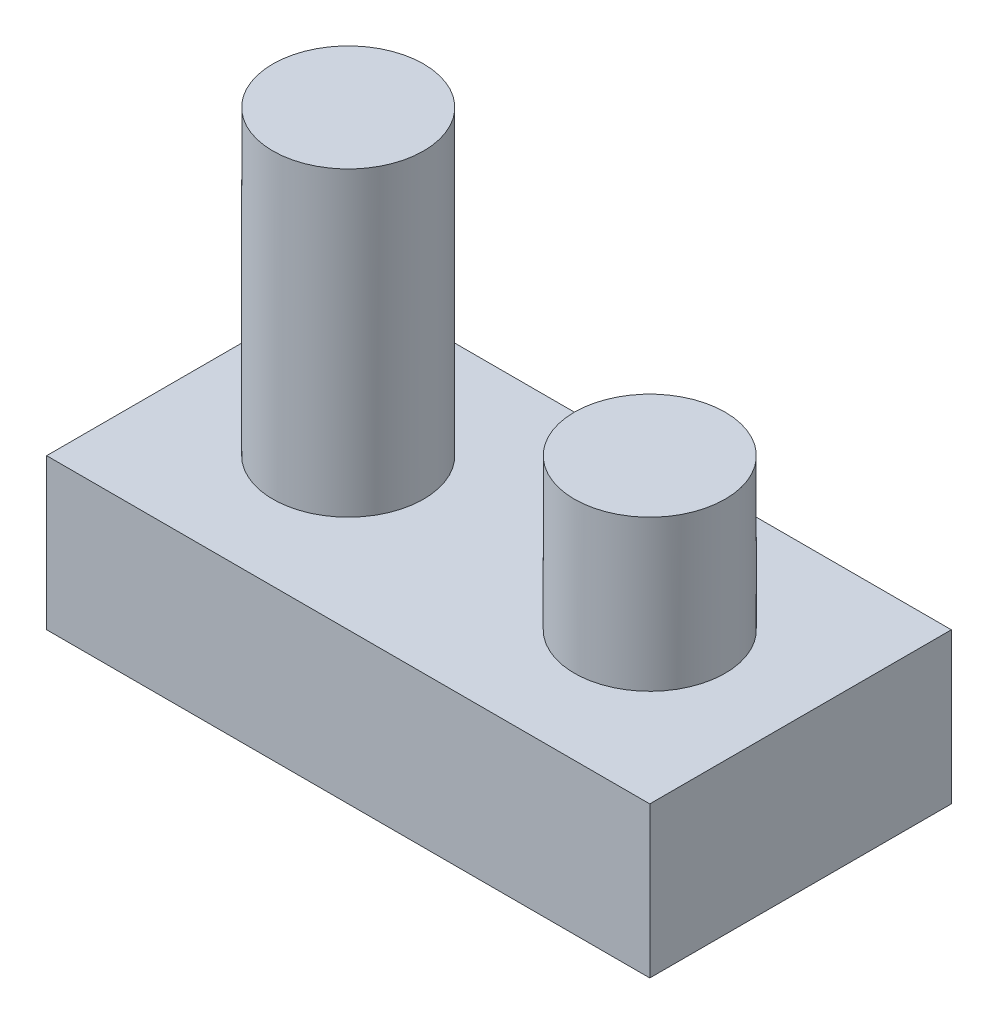
from build123d import *

# Parameters (mm, degrees)
SKETCH1_W           = 50.8
SKETCH1_H           = 25.4
BOSS_EXTRUDE1_DEPTH = 12.7
SKETCH2_R           = 6.35
BOSS_EXTRUDE2_DEPTH = 25.4
SKETCH3_R           = 6.35
BOSS_EXTRUDE3_DEPTH = 12.7


with BuildPart() as part:
    # Sketch1 → Boss-Extrude1 (new body)
    with BuildSketch(Plane(origin=(0, 0, 0), x_dir=(1, 0, 0), z_dir=(0, 1, 0))):
        Rectangle(SKETCH1_W, SKETCH1_H)
    extrude(amount=BOSS_EXTRUDE1_DEPTH)

    # Sketch2 → Boss-Extrude2 (add)
    with BuildSketch(Plane(origin=(0, 12.7, 0), x_dir=(1, 0, 0), z_dir=(0, 1, 0))):
        with Locations((-12.7, 0)):
            Circle(SKETCH2_R)
    extrude(amount=BOSS_EXTRUDE2_DEPTH)

    # Sketch3 → Boss-Extrude3 (add)
    with BuildSketch(Plane(origin=(0, 12.7, 0), x_dir=(1, 0, 0), z_dir=(0, 1, 0))):
        with Locations((12.7, 0)):
            Circle(SKETCH3_R)
    extrude(amount=BOSS_EXTRUDE3_DEPTH)


solid = part.part
